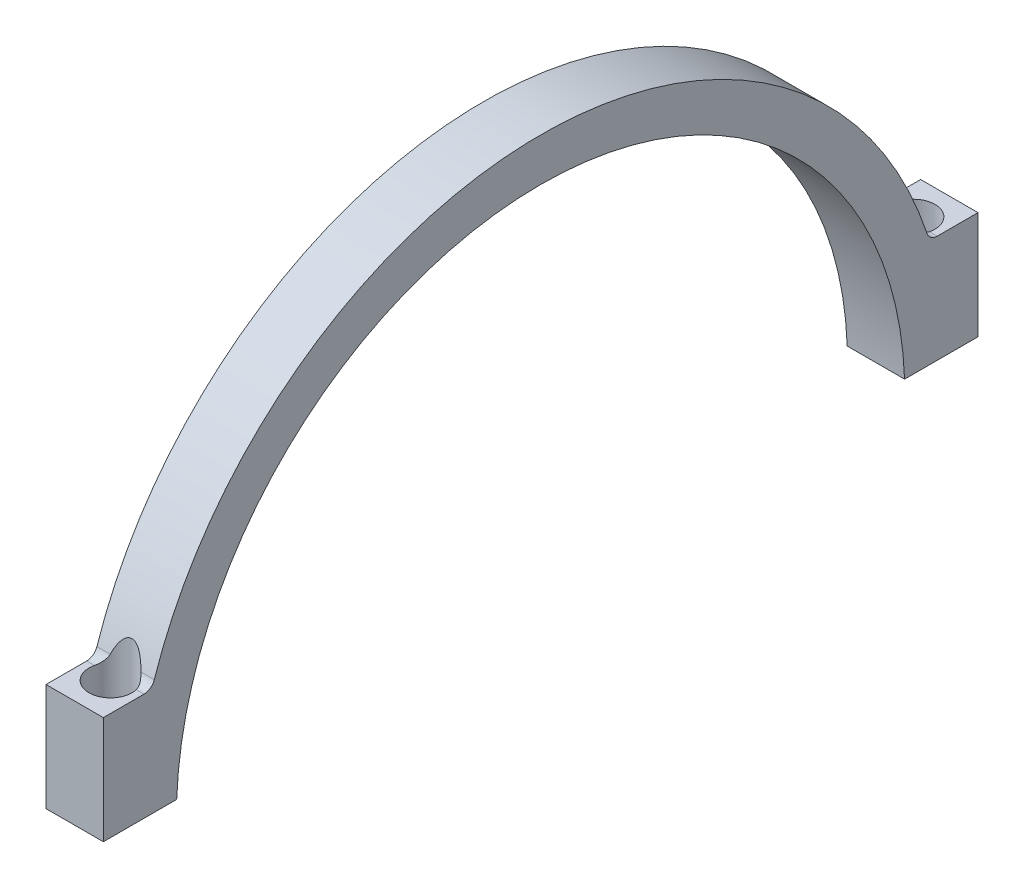
from build123d import *

# Parameters (mm, degrees)
BOSS_EXTRUDE1_DEPTH           = 8
M4_CLEARANCE_HOLE1_AT_2_COUNT = 2
M4_CLEARANCE_HOLE1_AT_2_PITCH = 112
SKETCH7_R                     = 3
CUT_EXTRUDE1_DEPTH            = 10
CUT_EXTRUDE1_DEPTH_BACK       = 6


with BuildPart() as part:
    # Sketch1 → Boss-Extrude1 (new body)
    with BuildSketch(Plane(origin=(0, 0, 0), x_dir=(0, 0, -1), z_dir=(1, 0, 0))):
        with BuildLine():
            Line((-60.995543931, 1.9), (-50.764456069, 1.9))
            ThreePointArc((-50.764456069, 1.9), (0, 50.8), (50.764456069, 1.9))
            Line((50.764456069, 1.9), (61.004456069, 1.9))
            Line((61.004456069, 1.9), (61.004456069, 16.9))
            Line((61.004456069, 16.9), (55.320249457, 16.9))
            ThreePointArc((55.320249457, 16.9), (54.442787227, 17.18342282), (53.896915423, 17.926586621))
            ThreePointArc((53.896915423, 17.926586621), (0, 56.8), (-53.896915423, 17.926586621))
            ThreePointArc((-53.896915423, 17.926586621), (-54.442787227, 17.18342282), (-55.320249457, 16.9))
            Line((-55.320249457, 16.9), (-60.995543931, 16.9))
            Line((-60.995543931, 16.9), (-60.995543931, 1.9))
        make_face()
    extrude(amount=BOSS_EXTRUDE1_DEPTH)

    # Sketch4 → M4 Clearance Hole1 (revolve, cut)
    with BuildSketch(Plane(origin=(4, 16.9, -56.004456069), x_dir=(0, 0, 1), z_dir=(1, 0, 0))):
        Polygon((0, 0), (0, 17.291850331), (2.15, 16), (2.15, 0), align=None)
    m4_clearance_hole1 = revolve(axis=Axis((4, 23.25, -56.004456069), (0, -1, 0)), mode=Mode.SUBTRACT)

    # M4 Clearance Hole1 at 2: M4 Clearance Hole1 ×2
    with Locations(*[(0, 0, i * M4_CLEARANCE_HOLE1_AT_2_PITCH) for i in range(1, M4_CLEARANCE_HOLE1_AT_2_COUNT)]):
        add(m4_clearance_hole1, mode=Mode.SUBTRACT)

    # Sketch7 → Cut-Extrude1 (cut, two sides)
    with BuildSketch(Plane(origin=(0, 16.9, 0), x_dir=(1, 0, 0), z_dir=(0, 1, 0))) as cut_extrude1_sk:
        with Locations((4, 56.004456069)):
            Circle(SKETCH7_R)
        with Locations((4, -55.995543931)):
            Circle(SKETCH7_R)
    extrude(amount=CUT_EXTRUDE1_DEPTH, mode=Mode.SUBTRACT)
    extrude(cut_extrude1_sk.sketch, amount=-CUT_EXTRUDE1_DEPTH_BACK, mode=Mode.SUBTRACT)


solid = part.part
